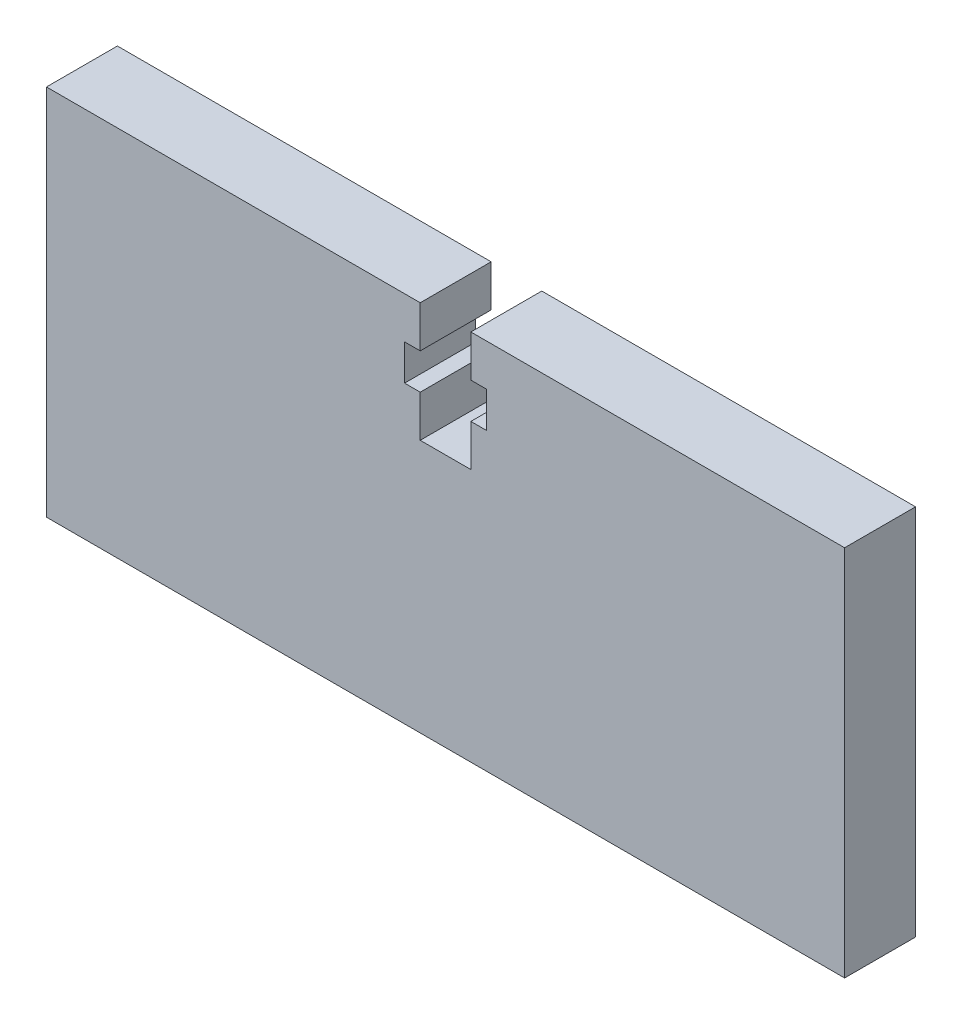
from build123d import *

# Parameters (mm, degrees)
BOSS_EXTRUDE1_DEPTH = 4.7625


with BuildPart() as part:
    # Sketch1 → Boss-Extrude1 (new body)
    with BuildSketch(Plane.XY):
        Polygon((-26.797, -8.51), (-26.797, 16.51), (-1.7, 16.51), (-1.7, 13.71), (-2.75, 13.71), (-2.75, 11.31), (-1.7, 11.31), (-1.7, 8.51), (1.7, 8.51), (1.7, 11.31), (2.75, 11.31), (2.75, 13.71), (1.7, 13.71), (1.7, 16.51), (26.797, 16.51), (26.797, -8.51), align=None)
    extrude(amount=BOSS_EXTRUDE1_DEPTH)


solid = part.part
